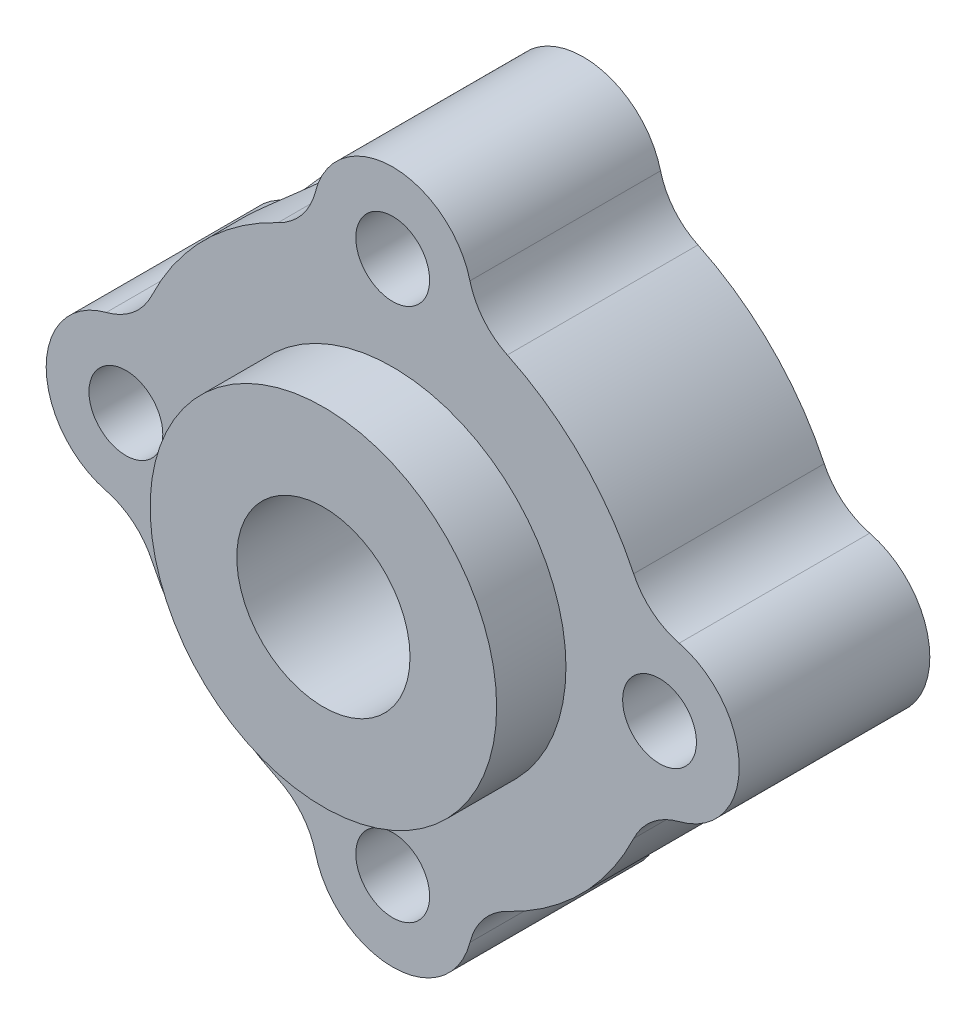
from build123d import *

# Parameters (mm, degrees)
BOSS_EXTRUDE2_DEPTH   = 6.985
FILLET3_R             = 2.54
SKETCH2_R             = 6.35
BOSS_EXTRUDE3_DEPTH   = 2.54
SKETCH3_R             = 3.175
CUT_EXTRUDE1_DEPTH    = 9.525
F_6_32_TAPPED_HOLE1_D = 2.7051
SKETCH12_R            = 2.159
CUT_EXTRUDE4_DEPTH    = 9.906


with BuildPart() as part:
    # Sketch1 → Boss-Extrude2 (new body)
    with BuildSketch(Plane.XY):
        with BuildLine():
            ThreePointArc((-21.795940027, 25.899130336), (-25.822498312, 23.471180796), (-28.250447852, 19.444622511))
            ThreePointArc((-28.250447852, 19.444622511), (-31.607701099, 16.556383583), (-28.250447852, 13.668144655))
            ThreePointArc((-28.250447852, 13.668144655), (-25.822498312, 9.64158637), (-21.795940027, 7.21363683))
            ThreePointArc((-21.795940027, 7.21363683), (-18.907701099, 3.856383583), (-16.019462171, 7.21363683))
            ThreePointArc((-16.019462171, 7.21363683), (-11.992903886, 9.64158637), (-9.564954346, 13.668144655))
            ThreePointArc((-9.564954346, 13.668144655), (-6.207701099, 16.556383583), (-9.564954346, 19.444622511))
            ThreePointArc((-9.564954346, 19.444622511), (-11.992903886, 23.471180796), (-16.019462171, 25.899130336))
            ThreePointArc((-16.019462171, 25.899130336), (-18.907701099, 29.256383583), (-21.795940027, 25.899130336))
        make_face()
    extrude(amount=BOSS_EXTRUDE2_DEPTH)

    # Fillet3
    fillet3_edges = [part.edges().sort_by_distance(p)[0] for p in [
        (-16.019462171, 7.21363683, 3.4925),
        (-21.795940027, 7.21363683, 3.4925),
        (-28.250447852, 13.668144655, 3.4925),
        (-28.250447852, 19.444622511, 3.4925),
        (-21.795940027, 25.899130336, 3.4925),
        (-16.019462171, 25.899130336, 3.4925),
        (-9.564954346, 19.444622511, 3.4925),
        (-9.564954346, 13.668144655, 3.4925),
    ]]
    fillet(fillet3_edges, radius=FILLET3_R)

    # Sketch2 → Boss-Extrude3 (add)
    with BuildSketch(Plane.XY.offset(6.985)):
        with Locations((-18.907701099, 16.556383583)):
            Circle(SKETCH2_R)
    extrude(amount=BOSS_EXTRUDE3_DEPTH)

    # Sketch3 → Cut-Extrude1 (cut)
    with BuildSketch(Plane.XY.offset(9.525)):
        with Locations((-18.907701099, 16.556383583)):
            Circle(SKETCH3_R)
    extrude(amount=-CUT_EXTRUDE1_DEPTH, mode=Mode.SUBTRACT)

    # #6-32 Tapped Hole1 (through all)
    with Locations(Plane(origin=(0, 0, 0), x_dir=(-1, 0, 0), z_dir=(0, 0, -1))):
        with Locations((18.907701099, 26.335383583), (28.686701099, 16.556383583), (18.907701099, 6.777383583), (9.128701099, 16.556383583)):
            Hole(F_6_32_TAPPED_HOLE1_D / 2)

    # Sketch12 → Cut-Extrude4 (cut)
    with BuildSketch(Plane(origin=(-24.434266922, 24.837342139, 0), x_dir=(0.712867541, 0.701298701, 0), z_dir=(-0.701298701, 0.712867541, 0))):
        with Locations((-1.965596828, -3.45963024)):
            Circle(SKETCH12_R)
    extrude(amount=-CUT_EXTRUDE4_DEPTH, mode=Mode.SUBTRACT)


solid = part.part
